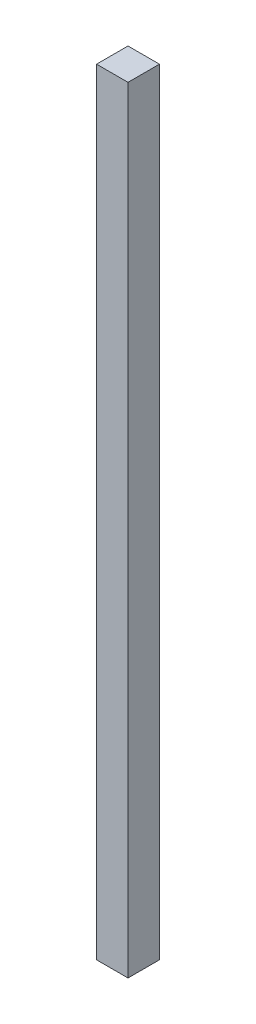
from build123d import *

# Parameters (mm, degrees)
SKETCH1_W           = 15
SKETCH1_H           = 15
BOSS_EXTRUDE1_DEPTH = 370


with BuildPart() as part:
    # Sketch1 → Boss-Extrude1 (new body)
    with BuildSketch(Plane(origin=(0, 0, 0), x_dir=(1, 0, 0), z_dir=(0, 1, 0))):
        Rectangle(SKETCH1_W, SKETCH1_H)
    extrude(amount=BOSS_EXTRUDE1_DEPTH)


solid = part.part
